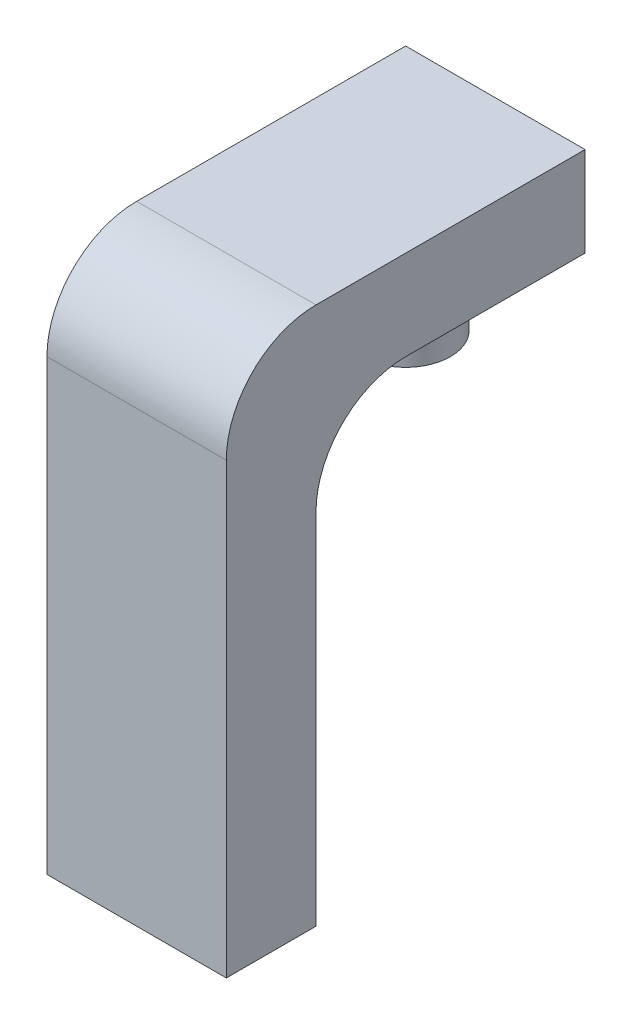
from build123d import *

# Parameters (mm, degrees)
SALIENTE_EXTRUIR1_DEPTH = 50.8
CROQUIS2_R              = 12.7
SALIENTE_EXTRUIR2_DEPTH = 19.05


with BuildPart() as part:
    # Croquis1 → Saliente-Extruir1 (new body)
    with BuildSketch(Plane(origin=(0, 0, 0), x_dir=(0, 0, -1), z_dir=(1, 0, 0))):
        with BuildLine():
            Line((0, 0), (25.4, 0))
            Line((25.4, 0), (25.4, 101.6))
            ThreePointArc((25.4, 101.6), (32.839487758, 119.560512242), (50.8, 127))
            Line((50.8, 127), (101.6, 127))
            Line((101.6, 127), (101.6, 152.4))
            Line((101.6, 152.4), (25.4, 152.4))
            ThreePointArc((25.4, 152.4), (7.439487758, 144.960512242), (0, 127))
            Line((0, 127), (0, 0))
        make_face()
    extrude(amount=SALIENTE_EXTRUIR1_DEPTH)

    # Croquis2 → Saliente-Extruir2 (add)
    with BuildSketch(Plane.XZ.offset(-127)):
        with Locations((25.4, -76.2)):
            Circle(CROQUIS2_R)
    extrude(amount=SALIENTE_EXTRUIR2_DEPTH)


solid = part.part
